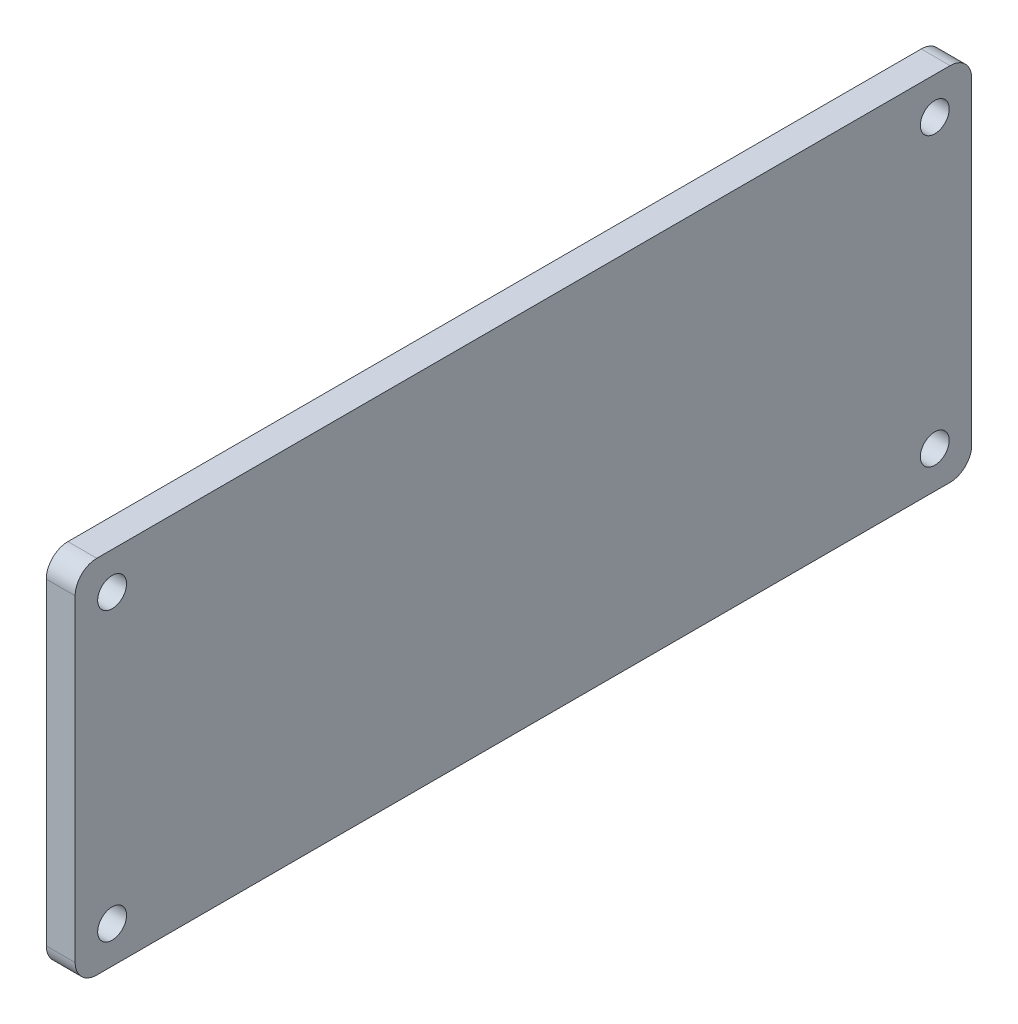
from build123d import *

# Parameters (mm, degrees)
SKETCH1_R           = 1
BOSS_EXTRUDE1_DEPTH = 2


with BuildPart() as part:
    # Sketch1 → Boss-Extrude1 (new body)
    with BuildSketch(Plane(origin=(0, 0, 0), x_dir=(0, 0, -1), z_dir=(1, 0, 0))):
        with BuildLine():
            Line((-29.55, -12.5), (29.55, -12.5))
            ThreePointArc((29.55, -12.5), (30.610660172, -12.060660172), (31.05, -11))
            Line((31.05, -11), (31.05, 11))
            ThreePointArc((31.05, 11), (30.610660172, 12.060660172), (29.55, 12.5))
            Line((29.55, 12.5), (-29.55, 12.5))
            ThreePointArc((-29.55, 12.5), (-30.610660172, 12.060660172), (-31.05, 11))
            Line((-31.05, 11), (-31.05, -11))
            ThreePointArc((-31.05, -11), (-30.610660172, -12.060660172), (-29.55, -12.5))
        make_face()
        with Locations((28.489339828, 9.939339828)):
            Circle(SKETCH1_R, mode=Mode.SUBTRACT)
        with Locations((-28.489339828, 9.939339828)):
            Circle(SKETCH1_R, mode=Mode.SUBTRACT)
        with Locations((28.489339828, -9.939339828)):
            Circle(SKETCH1_R, mode=Mode.SUBTRACT)
        with Locations((-28.489339828, -9.939339828)):
            Circle(SKETCH1_R, mode=Mode.SUBTRACT)
    extrude(amount=BOSS_EXTRUDE1_DEPTH)


solid = part.part
